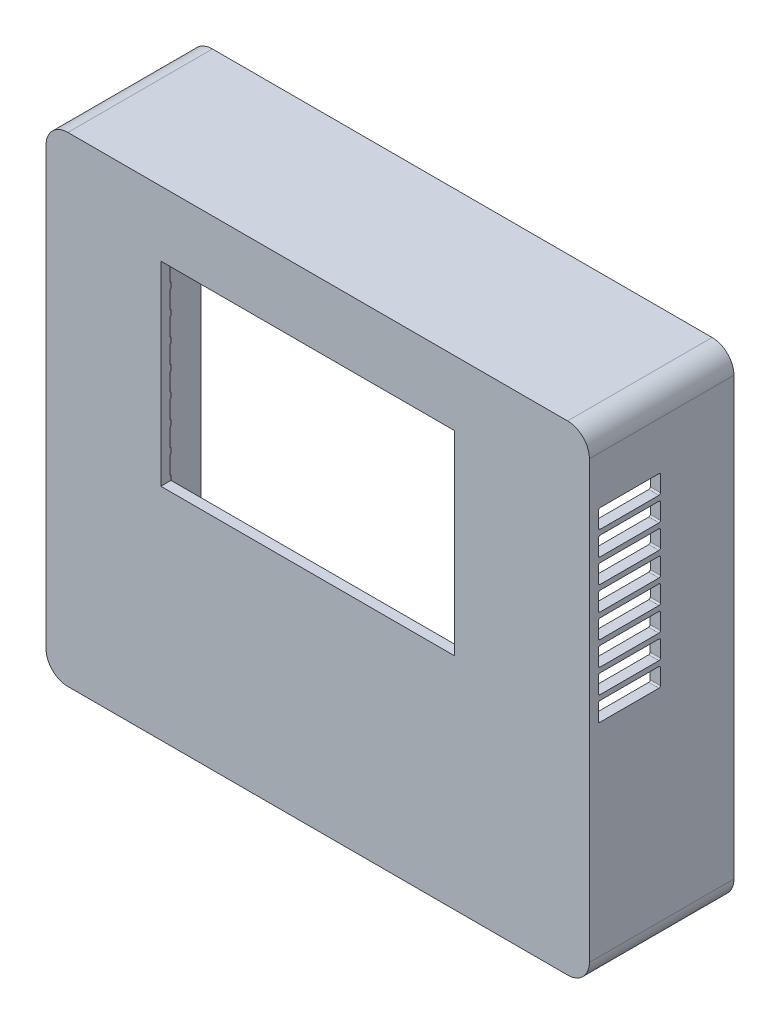
from build123d import *

# Parameters (mm, degrees)
SKETCH1_W           = 57.8
SKETCH1_H           = 38.4
BOSS_EXTRUDE3_DEPTH = 2
BOSS_EXTRUDE4_DEPTH = 28.466
SKETCH5_W           = 9.3
SKETCH5_H           = 11
SKETCH5_W_2         = 17.696
SKETCH5_H_2         = 6.81
SKETCH5_W_3         = 14.05
SKETCH5_H_3         = 16.84
SKETCH5_W_4         = 8.89
SKETCH5_H_4         = 3.43
CUT_EXTRUDE1_DEPTH  = 2
CUT_EXTRUDE2_DEPTH  = 108


with BuildPart() as part:
    # Sketch1 → Boss-Extrude3 (new body)
    with BuildSketch(Plane.XY):
        with BuildLine():
            Line((84, 51.09), (-14.4, 51.09))
            ThreePointArc((-14.4, 51.09), (-17.440559159, 49.830559159), (-18.7, 46.79))
            Line((-18.7, 46.79), (-18.7, -39.11))
            ThreePointArc((-18.7, -39.11), (-17.440559159, -42.150559159), (-14.4, -43.41))
            Line((-14.4, -43.41), (84, -43.41))
            ThreePointArc((84, -43.41), (87.040559159, -42.150559159), (88.3, -39.11))
            Line((88.3, -39.11), (88.3, 46.79))
            ThreePointArc((88.3, 46.79), (87.040559159, 49.830559159), (84, 51.09))
        make_face()
        with Locations((32.8, 19.1)):
            Rectangle(SKETCH1_W, SKETCH1_H, mode=Mode.SUBTRACT)
    extrude(amount=-BOSS_EXTRUDE3_DEPTH)

    # Sketch3 → Boss-Extrude4 (add)
    with BuildSketch(Plane.XY):
        with BuildLine():
            Line((84, 51.09), (-14.4, 51.09))
            ThreePointArc((-14.4, 51.09), (-17.440559159, 49.830559159), (-18.7, 46.79))
            Line((-18.7, 46.79), (-18.7, -39.11))
            ThreePointArc((-18.7, -39.11), (-17.440559159, -42.150559159), (-14.4, -43.41))
            Line((-14.4, -43.41), (84, -43.41))
            ThreePointArc((84, -43.41), (87.040559159, -42.150559159), (88.3, -39.11))
            Line((88.3, -39.11), (88.3, 46.79))
            ThreePointArc((88.3, 46.79), (87.040559159, 49.830559159), (84, 51.09))
        make_face()
        with BuildLine():
            Line((84, 49.09), (-14.4, 49.09))
            ThreePointArc((-14.4, 49.09), (-16.026345597, 48.416345597), (-16.7, 46.79))
            Line((-16.7, 46.79), (-16.7, -39.11))
            ThreePointArc((-16.7, -39.11), (-16.026345597, -40.736345597), (-14.4, -41.41))
            Line((-14.4, -41.41), (84, -41.41))
            ThreePointArc((84, -41.41), (85.626345597, -40.736345597), (86.3, -39.11))
            Line((86.3, -39.11), (86.3, 46.79))
            ThreePointArc((86.3, 46.79), (85.626345597, 48.416345597), (84, 49.09))
        make_face(mode=Mode.SUBTRACT)
    extrude(amount=-BOSS_EXTRUDE4_DEPTH)

    # Sketch5 → Cut-Extrude1 (cut)
    with BuildSketch(Plane.XZ.offset(43.41)):
        with Locations((-9.2, -22.796)):
            Rectangle(SKETCH5_W, SKETCH5_H)
        with Locations((7.56, -24.8148)):
            Rectangle(SKETCH5_W_2, SKETCH5_H_2)
        with Locations((27.4, -19.7998)):
            Rectangle(SKETCH5_W_3, SKETCH5_H_3)
        with Locations((44.4, -19.7998)):
            Rectangle(SKETCH5_W_3, SKETCH5_H_3)
        Polygon((68.12, -14.646007205), (66.12, -14.646007205), (57.38, -14.646007205), (55.38, -14.646007205), (53.673, -14.646007205), (53.673, -28.296), (55.38, -28.296), (57.38, -28.296), (66.12, -28.296), (68.12, -28.296), (69.827, -28.296), (69.827, -14.646007205), align=None)
        with Locations((76.775, -26.5048)):
            Rectangle(SKETCH5_W_4, SKETCH5_H_4)
    extrude(amount=-CUT_EXTRUDE1_DEPTH, mode=Mode.SUBTRACT)

    # Sketch6 → Cut-Extrude2 (cut, through all)
    with BuildSketch(Plane.ZY.offset(18.7)):
        with BuildLine():
            Line((-1.8, 34), (-1.8, 37.1))
            ThreePointArc((-1.8, 37.1), (-1.887867966, 37.312132034), (-2.1, 37.4))
            Line((-2.1, 37.4), (-13.7, 37.4))
            ThreePointArc((-13.7, 37.4), (-13.912132034, 37.312132034), (-14, 37.1))
            Line((-14, 37.1), (-14, 34))
            ThreePointArc((-14, 34), (-13.912132034, 33.787867966), (-13.7, 33.7))
            Line((-13.7, 33.7), (-2.1, 33.7))
            ThreePointArc((-2.1, 33.7), (-1.887867966, 33.787867966), (-1.8, 34))
        make_face()
        with BuildLine():
            Line((-1.796496345, 29.301871349), (-1.796496345, 32.401871349))
            ThreePointArc((-1.796496345, 32.401871349), (-1.88436431, 32.614003383), (-2.096496345, 32.701871349))
            Line((-2.096496345, 32.701871349), (-13.696496345, 32.701871349))
            ThreePointArc((-13.696496345, 32.701871349), (-13.908628379, 32.614003383), (-13.996496345, 32.401871349))
            Line((-13.996496345, 32.401871349), (-13.996496345, 29.301871349))
            ThreePointArc((-13.996496345, 29.301871349), (-13.908628379, 29.089739314), (-13.696496345, 29.001871349))
            Line((-13.696496345, 29.001871349), (-2.096496345, 29.001871349))
            ThreePointArc((-2.096496345, 29.001871349), (-1.88436431, 29.089739314), (-1.796496345, 29.301871349))
        make_face()
        with BuildLine():
            Line((-1.792992689, 24.603742697), (-1.792992689, 27.703742697))
            ThreePointArc((-1.792992689, 27.703742697), (-1.880860655, 27.915874732), (-2.092992689, 28.003742697))
            Line((-2.092992689, 28.003742697), (-13.692992689, 28.003742697))
            ThreePointArc((-13.692992689, 28.003742697), (-13.905124724, 27.915874732), (-13.992992689, 27.703742697))
            Line((-13.992992689, 27.703742697), (-13.992992689, 24.603742697))
            ThreePointArc((-13.992992689, 24.603742697), (-13.905124724, 24.391610663), (-13.692992689, 24.303742697))
            Line((-13.692992689, 24.303742697), (-2.092992689, 24.303742697))
            ThreePointArc((-2.092992689, 24.303742697), (-1.880860655, 24.391610663), (-1.792992689, 24.603742697))
        make_face()
        with BuildLine():
            Line((-1.789489034, 19.905614046), (-1.789489034, 23.005614046))
            ThreePointArc((-1.789489034, 23.005614046), (-1.877357, 23.21774608), (-2.089489034, 23.305614046))
            Line((-2.089489034, 23.305614046), (-13.689489034, 23.305614046))
            ThreePointArc((-13.689489034, 23.305614046), (-13.901621068, 23.21774608), (-13.989489034, 23.005614046))
            Line((-13.989489034, 23.005614046), (-13.989489034, 19.905614046))
            ThreePointArc((-13.989489034, 19.905614046), (-13.901621068, 19.693482012), (-13.689489034, 19.605614046))
            Line((-13.689489034, 19.605614046), (-2.089489034, 19.605614046))
            ThreePointArc((-2.089489034, 19.605614046), (-1.877357, 19.693482012), (-1.789489034, 19.905614046))
        make_face()
        with BuildLine():
            Line((-1.785985379, 15.207485395), (-1.785985379, 18.307485395))
            ThreePointArc((-1.785985379, 18.307485395), (-1.873853344, 18.519617429), (-2.085985379, 18.607485395))
            Line((-2.085985379, 18.607485395), (-13.685985379, 18.607485395))
            ThreePointArc((-13.685985379, 18.607485395), (-13.898117413, 18.519617429), (-13.985985379, 18.307485395))
            Line((-13.985985379, 18.307485395), (-13.985985379, 15.207485395))
            ThreePointArc((-13.985985379, 15.207485395), (-13.898117413, 14.99535336), (-13.685985379, 14.907485395))
            Line((-13.685985379, 14.907485395), (-2.085985379, 14.907485395))
            ThreePointArc((-2.085985379, 14.907485395), (-1.873853344, 14.99535336), (-1.785985379, 15.207485395))
        make_face()
        with BuildLine():
            Line((-1.782481723, 10.509356744), (-1.782481723, 13.609356744))
            ThreePointArc((-1.782481723, 13.609356744), (-1.870349689, 13.821488778), (-2.082481723, 13.909356744))
            Line((-2.082481723, 13.909356744), (-13.682481723, 13.909356744))
            ThreePointArc((-13.682481723, 13.909356744), (-13.894613758, 13.821488778), (-13.982481723, 13.609356744))
            Line((-13.982481723, 13.609356744), (-13.982481723, 10.509356744))
            ThreePointArc((-13.982481723, 10.509356744), (-13.894613758, 10.297224709), (-13.682481723, 10.209356744))
            Line((-13.682481723, 10.209356744), (-2.082481723, 10.209356744))
            ThreePointArc((-2.082481723, 10.209356744), (-1.870349689, 10.297224709), (-1.782481723, 10.509356744))
        make_face()
        with BuildLine():
            Line((-1.778978068, 5.811228092), (-1.778978068, 8.911228092))
            ThreePointArc((-1.778978068, 8.911228092), (-1.866846034, 9.123360127), (-2.078978068, 9.211228092))
            Line((-2.078978068, 9.211228092), (-13.678978068, 9.211228092))
            ThreePointArc((-13.678978068, 9.211228092), (-13.891110102, 9.123360127), (-13.978978068, 8.911228092))
            Line((-13.978978068, 8.911228092), (-13.978978068, 5.811228092))
            ThreePointArc((-13.978978068, 5.811228092), (-13.891110102, 5.599096058), (-13.678978068, 5.511228092))
            Line((-13.678978068, 5.511228092), (-2.078978068, 5.511228092))
            ThreePointArc((-2.078978068, 5.511228092), (-1.866846034, 5.599096058), (-1.778978068, 5.811228092))
        make_face()
        with BuildLine():
            Line((-1.775474413, 1.113099441), (-1.775474413, 4.213099441))
            ThreePointArc((-1.775474413, 4.213099441), (-1.863342378, 4.425231475), (-2.075474413, 4.513099441))
            Line((-2.075474413, 4.513099441), (-13.675474413, 4.513099441))
            ThreePointArc((-13.675474413, 4.513099441), (-13.887606447, 4.425231475), (-13.975474413, 4.213099441))
            Line((-13.975474413, 4.213099441), (-13.975474413, 1.113099441))
            ThreePointArc((-13.975474413, 1.113099441), (-13.887606447, 0.900967407), (-13.675474413, 0.813099441))
            Line((-13.675474413, 0.813099441), (-2.075474413, 0.813099441))
            ThreePointArc((-2.075474413, 0.813099441), (-1.863342378, 0.900967407), (-1.775474413, 1.113099441))
        make_face()
    extrude(amount=-CUT_EXTRUDE2_DEPTH, mode=Mode.SUBTRACT)


solid = part.part
